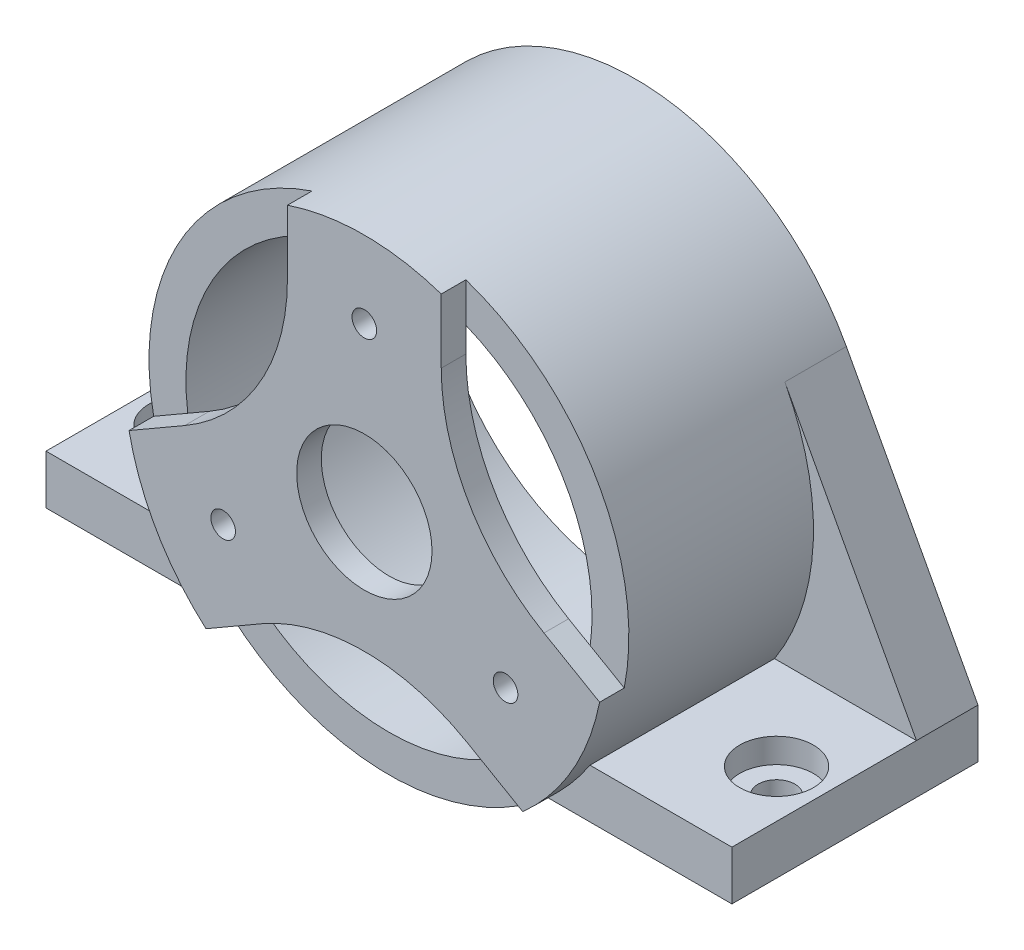
from build123d import *

# Parameters (mm, degrees)
SKETCH_1_R          = 5.5
SKETCH_1_R_2        = 1
EXTRUDE_1_DEPTH     = 2
EXTRUDE_START       = -20
EXTRUDE_2_DEPTH     = 20
EXTRUDE_3_DEPTH     = 20
SKETCH_6_W          = 15
SKETCH_6_H          = 20
EXTRUDE_9_DEPTH     = 4
EXTRUDE_10_DEPTH    = 5
EXTRUDE_11_DEPTH    = 5
SKETCH_9_R          = 1.5
CUT_EXTRUDE_3_DEPTH = 10
SKETCH_11_R         = 3
CUT_EXTRUDE_4_DEPTH = 2


with BuildPart() as part:
    # 草图1 → 凸台-拉伸1 (new body)
    with BuildSketch(Plane.XY):
        with BuildLine():
            Line((6.25, 13.25), (6.25, 18.471261462))
            ThreePointArc((6.25, 18.471261462), (0, 19.5), (-6.25, 18.471261462))
            Line((-6.25, 18.471261462), (-6.25, 13.25))
            ThreePointArc((-6.25, 13.25), (-8.487331974, 4.9001634), (-14.5998366, -1.212341226))
            Line((-14.5998366, -1.212341226), (-19.121581666, -3.822971957))
            ThreePointArc((-19.121581666, -3.822971957), (-16.887495374, -9.75), (-12.871581666, -14.648289505))
            Line((-12.871581666, -14.648289505), (-8.3498366, -12.037658774))
            ThreePointArc((-8.3498366, -12.037658774), (0, -9.8003268), (8.3498366, -12.037658774))
            Line((8.3498366, -12.037658774), (12.871581666, -14.648289505))
            ThreePointArc((12.871581666, -14.648289505), (16.887495374, -9.75), (19.121581666, -3.822971957))
            Line((19.121581666, -3.822971957), (14.5998366, -1.212341226))
            ThreePointArc((14.5998366, -1.212341226), (8.487331974, 4.9001634), (6.25, 13.25))
        make_face()
        Circle(SKETCH_1_R, mode=Mode.SUBTRACT)
        with Locations((0, 13.25)):
            Circle(SKETCH_1_R_2, mode=Mode.SUBTRACT)
        with Locations((11.4748366, -6.625)):
            Circle(SKETCH_1_R_2, mode=Mode.SUBTRACT)
        with Locations((-11.4748366, -6.625)):
            Circle(SKETCH_1_R_2, mode=Mode.SUBTRACT)
    extrude(amount=EXTRUDE_1_DEPTH)

    # 草图1<3> → 凸台-拉伸2 (add)
    with BuildSketch(Plane.XY.offset(EXTRUDE_START)):
        with BuildLine():
            Line((6.55834649, -15.140610665), (5.773502692, -16.5))
            Line((5.773502692, -16.5), (10.392304845, -16.5))
            ThreePointArc((10.392304845, -16.5), (0, 19.5), (-10.392304845, -16.5))
            Line((-10.392304845, -16.5), (-5.773502692, -16.5))
            Line((-5.773502692, -16.5), (-6.55834649, -15.140610665))
            ThreePointArc((-6.55834649, -15.140610665), (0, 16.5), (6.55834649, -15.140610665))
        make_face()
    extrude(amount=EXTRUDE_2_DEPTH)

    # 草图1<4> → 凸台-拉伸3 (add)
    with BuildSketch(Plane.XY.offset(EXTRUDE_START)):
        with BuildLine():
            Line((5.773502692, -16.5), (6.55834649, -15.140610665))
            ThreePointArc((6.55834649, -15.140610665), (0, -16.5), (-6.55834649, -15.140610665))
            Line((-6.55834649, -15.140610665), (-5.773502692, -16.5))
            Line((-5.773502692, -16.5), (-10.392304845, -16.5))
            ThreePointArc((-10.392304845, -16.5), (0, -19.5), (10.392304845, -16.5))
            Line((10.392304845, -16.5), (5.773502692, -16.5))
        make_face()
    extrude(amount=EXTRUDE_3_DEPTH)

    # 草图6 → 凸台-拉伸9 (add)
    with BuildSketch(Plane(origin=(0, -14.648289505, 0), x_dir=(1, 0, 0), z_dir=(0, 1, 0))):
        with Locations((-20.371581666, 10)):
            Rectangle(SKETCH_6_W, SKETCH_6_H)
        with Locations((20.371581666, 10)):
            Rectangle(SKETCH_6_W, SKETCH_6_H)
    extrude(amount=EXTRUDE_9_DEPTH)

    # 草图8 → 凸台-拉伸10 (add)
    with BuildSketch(Plane(origin=(0, 0, -20), x_dir=(-1, 0, 0), z_dir=(0, 0, -1))):
        with BuildLine():
            Line((-17.172554049, 9.238689703), (-27.871581666, -10.648289505))
            Line((-27.871581666, -10.648289505), (-16.335970452, -10.648289505))
            ThreePointArc((-16.335970452, -10.648289505), (-19.48276903, -0.819579727), (-17.172554049, 9.238689703))
        make_face()
    extrude(amount=-EXTRUDE_10_DEPTH)

    # 草图8<3> → 凸台-拉伸11 (add)
    with BuildSketch(Plane(origin=(0, 0, -20), x_dir=(-1, 0, 0), z_dir=(0, 0, -1))):
        with BuildLine():
            Line((27.871581666, -10.648289505), (17.172554049, 9.238689703))
            ThreePointArc((17.172554049, 9.238689703), (19.48276903, -0.819579727), (16.335970452, -10.648289505))
            Line((16.335970452, -10.648289505), (27.871581666, -10.648289505))
        make_face()
    extrude(amount=-EXTRUDE_11_DEPTH)

    # 草图9 → 切除-拉伸3 (cut)
    with BuildSketch(Plane(origin=(0, -10.648289505, 0), x_dir=(1, 0, 0), z_dir=(0, 1, 0))):
        with Locations((24, 7.5)):
            Circle(SKETCH_9_R)
        with Locations((-24, 7.5)):
            Circle(SKETCH_9_R)
    extrude(amount=-CUT_EXTRUDE_3_DEPTH, mode=Mode.SUBTRACT)

    # 草图11 → 切除-拉伸4 (cut)
    with BuildSketch(Plane(origin=(0, -10.648289505, 0), x_dir=(1, 0, 0), z_dir=(0, 1, 0))):
        with Locations((-24, 7.5)):
            Circle(SKETCH_11_R)
        with Locations((24, 7.5)):
            Circle(SKETCH_11_R)
    extrude(amount=-CUT_EXTRUDE_4_DEPTH, mode=Mode.SUBTRACT)


solid = part.part
